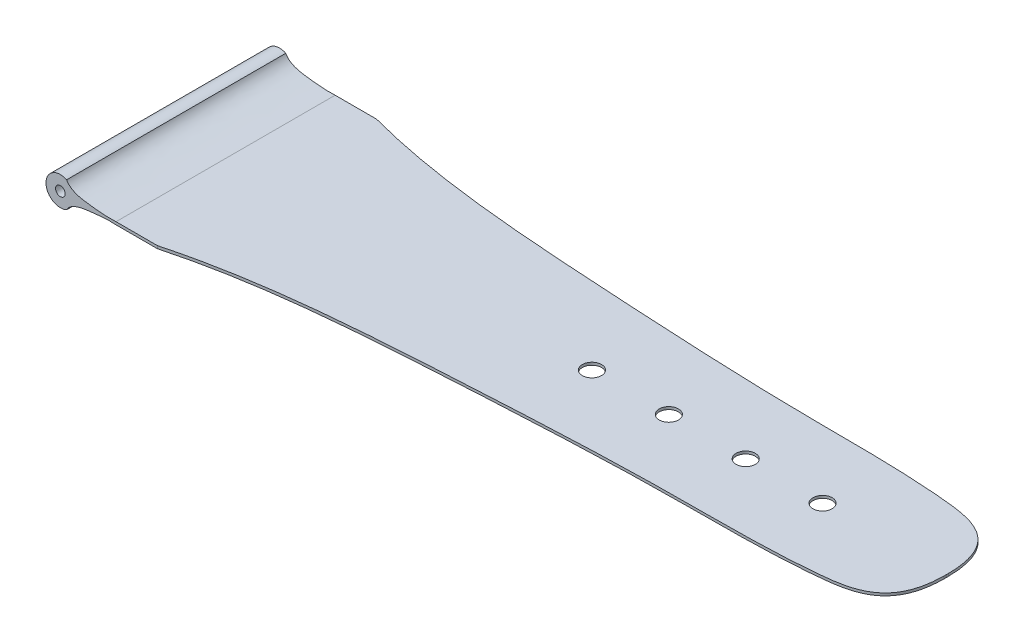
from build123d import *

# Parameters (mm, degrees)
ESQUISSE2_R                  = 0.5
BOSS_EXTRU_1_DEPTH           = 11.4
BOSS_EXTRU_1_DEPTH_BACK      = 11.4
ENL_V_MAT_EXTRU_1_DEPTH      = 2.3667646
ENL_V_MAT_EXTRU_1_DEPTH_BACK = 2.642922663
ESQUISSE4_R                  = 1
ENL_V_MAT_EXTRU_2_DEPTH      = 10


with BuildPart() as part:
    # Esquisse2 → Boss.-Extru.1 (new body, two sides)
    with BuildSketch(Plane.XY) as boss_extru_1_sk:
        with BuildLine():
            Line((5.791060422, 0.142064292), (80.791060422, 0.133235508))
            ThreePointArc((80.791060422, 0.133235508), (80.791208073, 0), (80.791060422, -0.133235508))
            Line((80.791060422, -0.133235508), (5.791060422, -0.142064292))
            add(Edge.make_bspline(
                [(0.650938463, -1.351398948), (1.114517622, -0.510365175), (3.069897688, -0.268204079), (5.029284194, -0.087299538), (5.791060422, -0.142064292)],
                knots=[0, 0, 0, 0, 0.614720571, 1, 1, 1, 1], degree=3))
            ThreePointArc((0.650938463, -1.351398948), (-1.5, 0), (0.650938463, 1.351398948))
            add(Edge.make_bspline(
                [(0.650938463, 1.351398948), (1.114517622, 0.510365175), (3.069897688, 0.268204079), (5.029284194, 0.087299538), (5.791060422, 0.142064292)],
                knots=[0, 0, 0, 0, 0.614720571, 1, 1, 1, 1], degree=3))
        make_face()
        Circle(ESQUISSE2_R, mode=Mode.SUBTRACT)
    extrude(amount=BOSS_EXTRU_1_DEPTH)
    extrude(boss_extru_1_sk.sketch, amount=-BOSS_EXTRU_1_DEPTH_BACK)

    # Esquisse3 → Enl_v. mat.-Extru.1 (cut, two sides)
    with BuildSketch(Plane(origin=(1.6804e-05, 0.142745997, 0), x_dir=(0.999999993, -0.000117717, 0), z_dir=(0.000117717, 0.999999993, 0))) as enl_v_mat_extru_1_sk:
        with BuildLine():
            Line((10.102155287, -11.4), (10.102155287, -17.099052468))
            Line((10.102155287, -17.099052468), (86.344524323, -17.099052468))
            Line((86.344524323, -17.099052468), (86.344524323, 15.270652799))
            Line((86.344524323, 15.270652799), (10.102155287, 15.270652799))
            Line((10.102155287, 15.270652799), (10.102155287, 11.4))
            add(Edge.make_bspline(
                [(10.102155287, 11.4), (17.187955459, 9.505905963), (27.807117465, 8.474072417), (44.021133961, 7.54546899), (58.105257919, 6.872044623), (72.14311084, 7.164739919), (80.839785674, 5.702525327), (80.791044178, 0)],
                knots=[0, 0, 0, 0, 0.29559869, 0.428617279, 0.656429752, 0.863093906, 1, 1, 1, 1], degree=3))
            add(Edge.make_bspline(
                [(10.102155287, -11.4), (17.187955459, -9.505905963), (27.807117465, -8.474072417), (44.021133961, -7.54546899), (58.105257919, -6.872044623), (72.14311084, -7.164739919), (80.839785674, -5.702525327), (80.791044178, 0)],
                knots=[0, 0, 0, 0, 0.29559869, 0.428617279, 0.656429752, 0.863093906, 1, 1, 1, 1], degree=3))
        make_face()
    extrude(amount=ENL_V_MAT_EXTRU_1_DEPTH, mode=Mode.SUBTRACT)
    extrude(enl_v_mat_extru_1_sk.sketch, amount=-ENL_V_MAT_EXTRU_1_DEPTH_BACK, mode=Mode.SUBTRACT)

    # Esquisse4 → Enl_v. mat.-Extru.2 (cut)
    with BuildSketch(Plane(origin=(1.6804e-05, 0.142745997, 0), x_dir=(0.999999993, -0.000117717, 0), z_dir=(0.000117717, 0.999999993, 0))):
        with Locations((67.918028656, 0)):
            Circle(ESQUISSE4_R)
        with Locations((59.918028656, 0)):
            Circle(ESQUISSE4_R)
        with Locations((51.918028656, 0)):
            Circle(ESQUISSE4_R)
        with Locations((43.918028656, 0)):
            Circle(ESQUISSE4_R)
    extrude(amount=-ENL_V_MAT_EXTRU_2_DEPTH, mode=Mode.SUBTRACT)


solid = part.part
